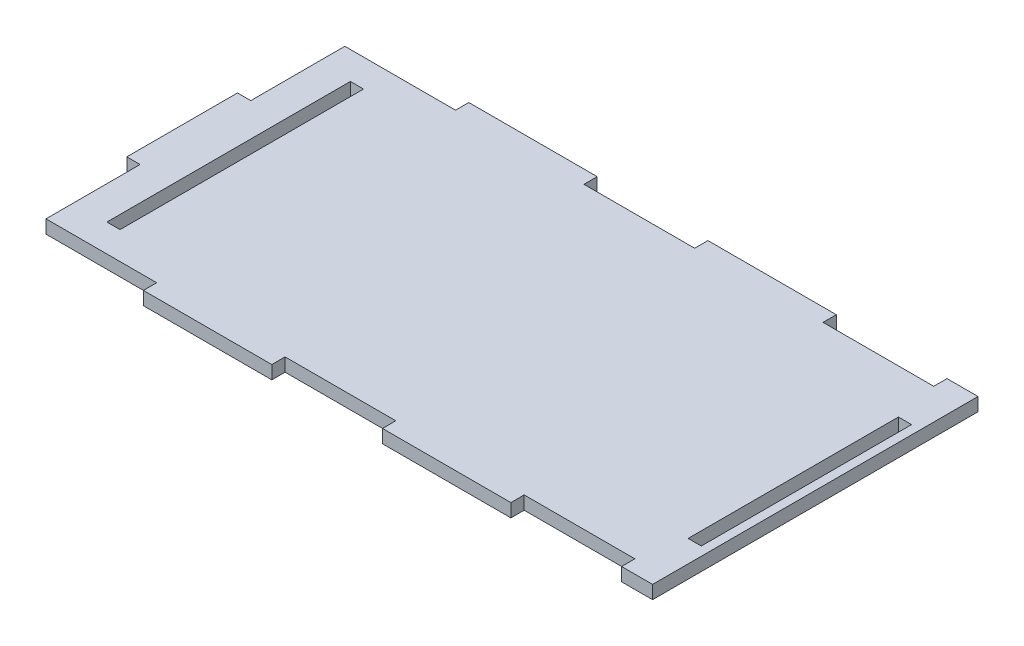
from build123d import *

# Parameters (mm, degrees)
SALIENTE_EXTRUIR1_DEPTH = 6
CROQUIS2_W              = 58
CROQUIS2_H              = 6
SALIENTE_EXTRUIR2_DEPTH = 6
CROQUIS3_W              = 6
CROQUIS3_H              = 50
SALIENTE_EXTRUIR3_DEPTH = 6
CROQUIS5_W              = 5.95
CROQUIS5_H              = 110
CORTAR_EXTRUIR2_DEPTH   = 7
CROQUIS6_W              = 147
CROQUIS6_H              = 6
SALIENTE_EXTRUIR4_DEPTH = 14
CROQUIS7_W              = 5.95
CROQUIS7_H              = 95
CORTAR_EXTRUIR3_DEPTH   = 7


with BuildPart() as part:
    # Croquis1 → Saliente-Extruir1 (new body)
    with BuildSketch(Plane(origin=(0, 0, 0), x_dir=(1, 0, 0), z_dir=(0, 1, 0))):
        Polygon((-83, 67.5), (-133, 67.5), (-133, 25), (-133, -25), (-133, -67.5), (133, -67.5), (133, 67.5), (72.5, 67.5), (25, 67.5), (-25, 67.5), align=None)
    extrude(amount=SALIENTE_EXTRUIR1_DEPTH)

    # Croquis2 → Saliente-Extruir2 (add)
    with BuildSketch(Plane(origin=(0, 6, 0), x_dir=(1, 0, 0), z_dir=(0, 1, 0))):
        with Locations((-54, 70.5)):
            Rectangle(CROQUIS2_W, CROQUIS2_H)
        with Locations((54, 70.5)):
            Rectangle(CROQUIS2_W, CROQUIS2_H)
        with Locations((-54, -70.5)):
            Rectangle(CROQUIS2_W, CROQUIS2_H)
        with Locations((54, -70.5)):
            Rectangle(CROQUIS2_W, CROQUIS2_H)
    extrude(amount=-SALIENTE_EXTRUIR2_DEPTH)

    # Croquis3 → Saliente-Extruir3 (add)
    with BuildSketch(Plane(origin=(0, 6, 0), x_dir=(1, 0, 0), z_dir=(0, 1, 0))):
        with Locations((-136, 0)):
            Rectangle(CROQUIS3_W, CROQUIS3_H)
    extrude(amount=-SALIENTE_EXTRUIR3_DEPTH)

    # Croquis5 → Cortar-Extruir2 (cut, through all)
    with BuildSketch(Plane(origin=(0, 6, 0), x_dir=(1, 0, 0), z_dir=(0, 1, 0))):
        with Locations((-115.025, 0)):
            Rectangle(CROQUIS5_W, CROQUIS5_H)
    extrude(amount=-CORTAR_EXTRUIR2_DEPTH, mode=Mode.SUBTRACT)

    # Croquis6 → Saliente-Extruir4 (add)
    with BuildSketch(Plane(origin=(133, 0, 0), x_dir=(0, 0, -1), z_dir=(1, 0, 0))):
        with Locations((0, 3)):
            Rectangle(CROQUIS6_W, CROQUIS6_H)
    extrude(amount=SALIENTE_EXTRUIR4_DEPTH)

    # Croquis7 → Cortar-Extruir3 (cut, through all)
    with BuildSketch(Plane(origin=(0, 6, 0), x_dir=(1, 0, 0), z_dir=(0, 1, 0))):
        with Locations((140.025, 0)):
            Rectangle(CROQUIS7_W, CROQUIS7_H)
    extrude(amount=-CORTAR_EXTRUIR3_DEPTH, mode=Mode.SUBTRACT)


solid = part.part
